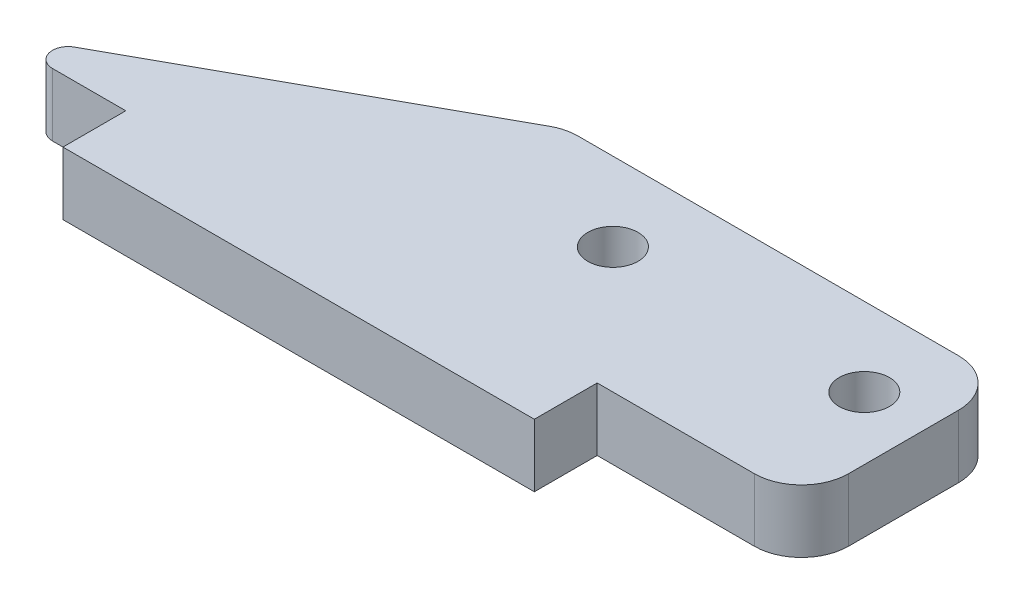
from build123d import *

# Parameters (mm, degrees)
SKETCH_1_R      = 1.6
EXTRUDE_1_DEPTH = 4
FILLET_1_R      = 3
FILLET_2_R      = 1


with BuildPart() as part:
    # ｽｹｯﾁ1 → ﾎﾞｽ - 押し出し1 (new body)
    with BuildSketch(Plane(origin=(0, 0, 0), x_dir=(1, 0, 0), z_dir=(0, 1, 0))):
        Polygon((-15, -4), (0, -4), (15, -4), (15, 0), (28, 0), (28, 13), (0, 13), (-23.545815275, 0), (-15, 0), align=None)
        with Locations((8, 8)):
            Circle(SKETCH_1_R, mode=Mode.SUBTRACT)
        with Locations((24, 8)):
            Circle(SKETCH_1_R, mode=Mode.SUBTRACT)
    extrude(amount=EXTRUDE_1_DEPTH)

    # ﾌｨﾚｯﾄ1
    fillet_1_edges = [part.edges().sort_by_distance(p)[0] for p in [
        (0, 2, -13),
        (28, 2, -13),
        (28, 2, 0),
    ]]
    fillet(fillet_1_edges, radius=FILLET_1_R)

    # ﾌｨﾚｯﾄ2
    fillet_2_edges = [part.edges().sort_by_distance(p)[0] for p in [
        (-23.545815275, 2, 0),
    ]]
    fillet(fillet_2_edges, radius=FILLET_2_R)


solid = part.part
